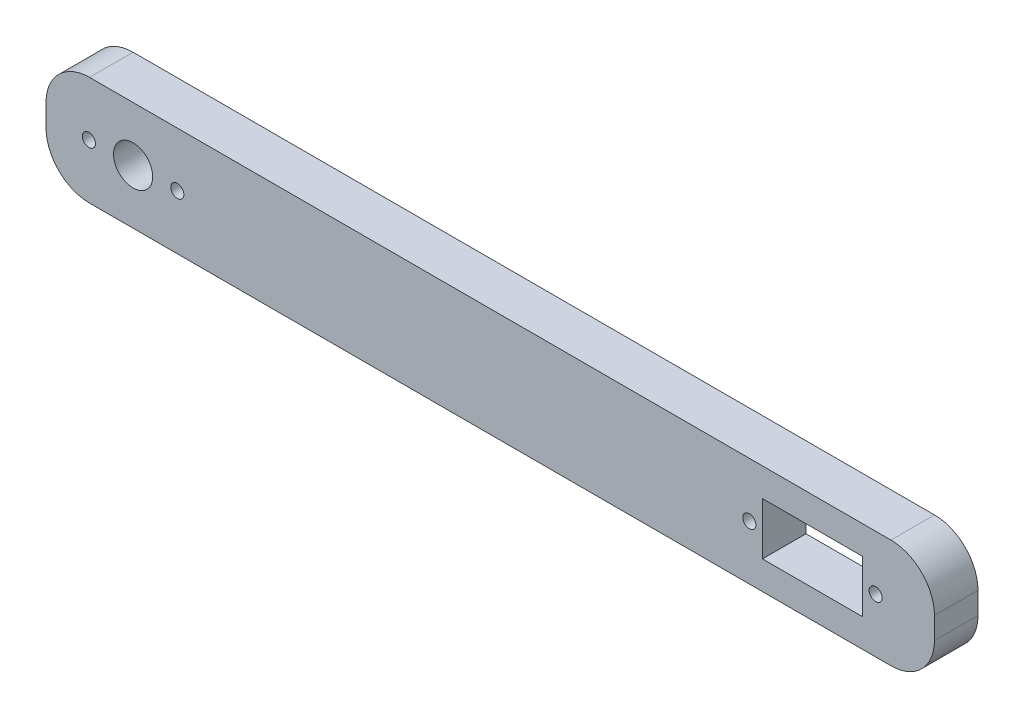
from build123d import *

# Parameters (mm, degrees)
SKETCH2_R           = 1.5
SKETCH2_R_2         = 4.5
BOSS_EXTRUDE1_DEPTH = 10


with BuildPart() as part:
    # Sketch2 → Boss-Extrude1 (new body)
    with BuildSketch(Plane.XY):
        with BuildLine():
            Line((-56.660710118, 0), (0, 0))
            Line((0, 0), (127.339289882, 0))
            ThreePointArc((127.339289882, 0), (134.410357694, 2.928932188), (137.339289882, 10))
            Line((137.339289882, 10), (137.339289882, 15))
            ThreePointArc((137.339289882, 15), (134.410357694, 22.071067812), (127.339289882, 25))
            Line((127.339289882, 25), (-56.660710118, 25))
            ThreePointArc((-56.660710118, 25), (-63.73177793, 22.071067812), (-66.660710118, 15))
            Line((-66.660710118, 15), (-66.660710118, 10))
            ThreePointArc((-66.660710118, 10), (-63.73177793, 2.928932188), (-56.660710118, 0))
        make_face()
        Polygon((97.839289882, 6.5), (97.839289882, 12.5), (97.839289882, 18.5), (120.839289882, 18.5), (120.839289882, 12.5), (120.839289882, 6.5), align=None, mode=Mode.SUBTRACT)
        with Locations((-56.810710118, 12.5)):
            Circle(SKETCH2_R, mode=Mode.SUBTRACT)
        with Locations((-46.660710118, 12.5)):
            Circle(SKETCH2_R_2, mode=Mode.SUBTRACT)
        with Locations((-36.510710118, 12.5)):
            Circle(SKETCH2_R, mode=Mode.SUBTRACT)
        with BuildLine():
            ThreePointArc((96.099859372, 13.312997269), (96.278187765, 12.923760406), (96.339289882, 12.5))
            ThreePointArc((96.339289882, 12.5), (93.400391999, 12.076239594), (96.099859372, 13.312997269))
        make_face(mode=Mode.SUBTRACT)
        with BuildLine():
            ThreePointArc((125.339289882, 12.5), (123.839289882, 11), (122.339289882, 12.5))
            ThreePointArc((122.339289882, 12.5), (122.373700536, 12.819449323), (122.475353708, 13.124242033))
            ThreePointArc((122.475353708, 13.124242033), (124.158739205, 13.965589346), (125.339289882, 12.5))
        make_face(mode=Mode.SUBTRACT)
    extrude(amount=BOSS_EXTRUDE1_DEPTH)


solid = part.part
